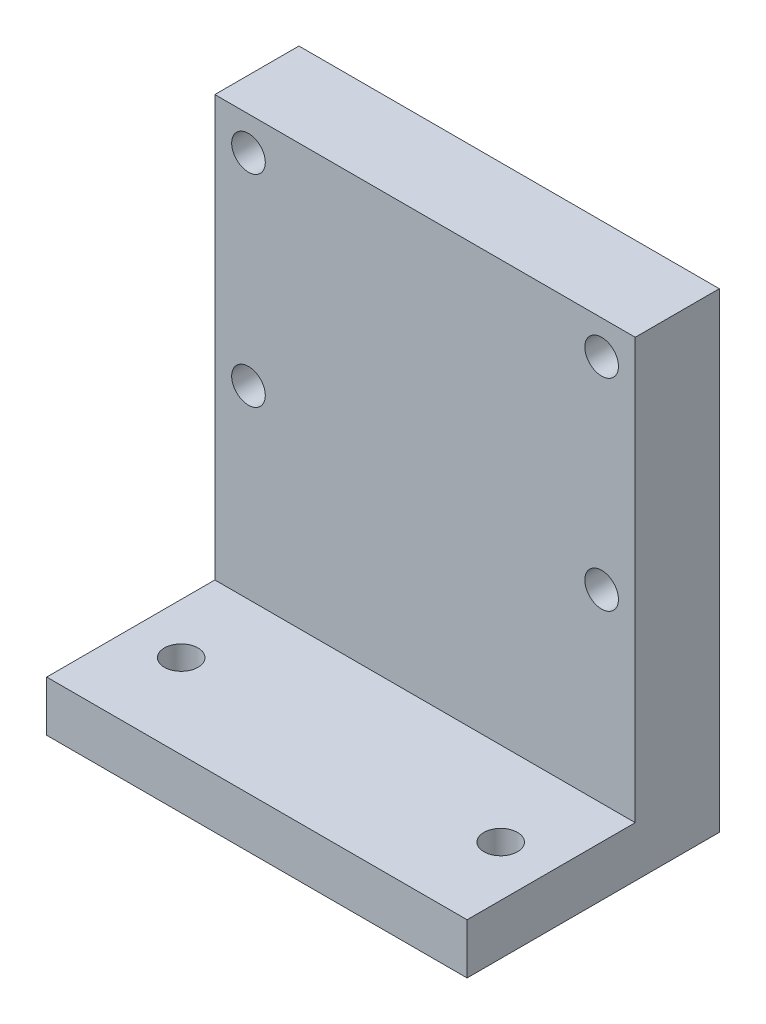
from build123d import *

# Parameters (mm, degrees)
SKETCH2_W           = 25
SKETCH2_H           = 35
BOSS_EXTRUDE2_DEPTH = 35
SKETCH3_W           = 25
SKETCH3_H           = 25
CUT_EXTRUDE1_DEPTH  = 25
SKETCH5_W           = 25
SKETCH5_H           = 10
CUT_EXTRUDE2_DEPTH  = 15
SKETCH6_R           = 1
CUT_EXTRUDE3_DEPTH  = 15
SKETCH7_W           = 25
SKETCH7_H           = 20
CUT_EXTRUDE4_DEPTH  = 7
SKETCH9_R           = 1
CUT_EXTRUDE6_DEPTH  = 15
SKETCH10_W          = 25
SKETCH10_H          = 28
CUT_EXTRUDE7_DEPTH  = 5


with BuildPart() as part:
    # Sketch2 → Boss-Extrude2 (new body)
    with BuildSketch(Plane.XY):
        with Locations((-5.377094972, 0.097765363)):
            Rectangle(SKETCH2_W, SKETCH2_H)
    extrude(amount=BOSS_EXTRUDE2_DEPTH)

    # Sketch3 → Cut-Extrude1 (cut)
    with BuildSketch(Plane.XY.offset(35)):
        with Locations((-5.377094972, 5.097765363)):
            Rectangle(SKETCH3_W, SKETCH3_H)
    extrude(amount=-CUT_EXTRUDE1_DEPTH, mode=Mode.SUBTRACT)

    # Sketch5 → Cut-Extrude2 (cut)
    with BuildSketch(Plane.XY.offset(35)):
        with Locations((-5.377094972, -12.402234637)):
            Rectangle(SKETCH5_W, SKETCH5_H)
    extrude(amount=-CUT_EXTRUDE2_DEPTH, mode=Mode.SUBTRACT)

    # Sketch6 → Cut-Extrude3 (cut)
    with BuildSketch(Plane(origin=(0, -7.402234637, 0), x_dir=(1, 0, 0), z_dir=(0, 1, 0))):
        with Locations((-14.877924678, -15)):
            Circle(SKETCH6_R)
        with Locations((4.122905028, -15)):
            Circle(SKETCH6_R)
    extrude(amount=-CUT_EXTRUDE3_DEPTH, mode=Mode.SUBTRACT)

    # Sketch7 → Cut-Extrude4 (cut)
    with BuildSketch(Plane.XZ.offset(17.402234637)):
        with Locations((-5.377094972, 10)):
            Rectangle(SKETCH7_W, SKETCH7_H)
    extrude(amount=-CUT_EXTRUDE4_DEPTH, mode=Mode.SUBTRACT)

    # Sketch9 → Cut-Extrude6 (cut)
    with BuildSketch(Plane.XY.offset(10)):
        with Locations((-15.877094972, 15.597765363)):
            Circle(SKETCH9_R)
        with Locations((5.122905028, 15.597765363)):
            Circle(SKETCH9_R)
        with Locations((-15.877094972, 3.597765363)):
            Circle(SKETCH9_R)
        with Locations((5.122905028, 3.597765363)):
            Circle(SKETCH9_R)
    extrude(amount=-CUT_EXTRUDE6_DEPTH, mode=Mode.SUBTRACT)

    # Sketch10 → Cut-Extrude7 (cut)
    with BuildSketch(Plane(origin=(0, 0, 0), x_dir=(-1, 0, 0), z_dir=(0, 0, -1))):
        with Locations((5.377094972, 3.597765363)):
            Rectangle(SKETCH10_W, SKETCH10_H)
    extrude(amount=-CUT_EXTRUDE7_DEPTH, mode=Mode.SUBTRACT)


solid = part.part
